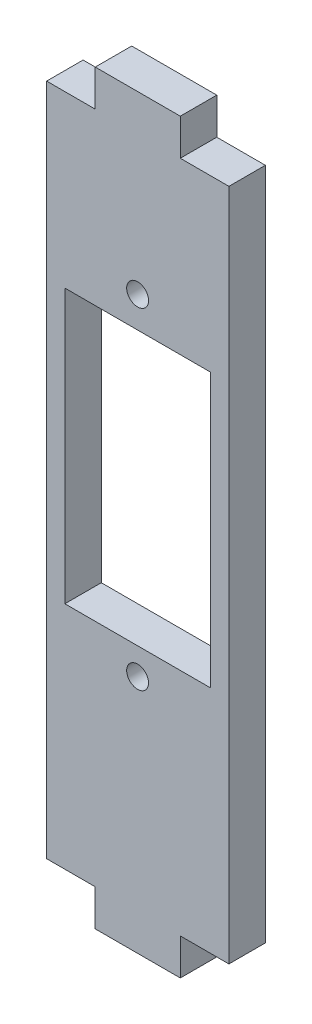
from build123d import *

# Parameters (mm, degrees)
SKETCH1_W               = 15
SKETCH1_H               = 61.42
BOSS_EXTRUDE2_DEPTH     = 3
SKETCH4_W               = 4
SKETCH4_H               = 3
CUT_EXTRUDE2_DEPTH      = 3
MIRROR2_COPY_1_SKETCH_W = 4
MIRROR2_COPY_1_SKETCH_H = 3
MIRROR2_COPY_1_DEPTH    = 3
SKETCH5_W               = 12
SKETCH5_H               = 22.5
CUT_EXTRUDE3_DEPTH      = 3
SKETCH7_R               = 0.9
CUT_EXTRUDE4_DEPTH      = 4


with BuildPart() as part:
    # Sketch1 → Boss-Extrude2 (new body)
    with BuildSketch(Plane.XY):
        Rectangle(SKETCH1_W, SKETCH1_H)
    extrude(amount=BOSS_EXTRUDE2_DEPTH)

    # Sketch4 → Cut-Extrude2 (cut)
    with BuildSketch(Plane.XY.offset(3)):
        with Locations((-5.5, 29.21)):
            Rectangle(SKETCH4_W, SKETCH4_H)
    cut_extrude2 = extrude(amount=-CUT_EXTRUDE2_DEPTH, mode=Mode.SUBTRACT)

    # Mirror1: Cut-Extrude2 across plane
    add(cut_extrude2.mirror(Plane(origin=(0, 0, 0), x_dir=(0, 0, 1), z_dir=(1, 0, 0))), mode=Mode.SUBTRACT)

    # Mirror2: Cut-Extrude2 across plane
    add(cut_extrude2.mirror(Plane.ZX), mode=Mode.SUBTRACT)

    # Mirror2 copy 1 sketch → Mirror2 copy 1 (cut)
    with BuildSketch(Plane(origin=(0, 0, 3), x_dir=(-1, 0, 0), z_dir=(0, 0, 1))):
        with Locations((-5.5, 29.21)):
            Rectangle(MIRROR2_COPY_1_SKETCH_W, MIRROR2_COPY_1_SKETCH_H)
    extrude(amount=-MIRROR2_COPY_1_DEPTH, mode=Mode.SUBTRACT)

    # Sketch5 → Cut-Extrude3 (cut)
    with BuildSketch(Plane.XY.offset(3)):
        with Locations((0, 2.46)):
            Rectangle(SKETCH5_W, SKETCH5_H)
    extrude(amount=-CUT_EXTRUDE3_DEPTH, mode=Mode.SUBTRACT)

    # Sketch7 → Cut-Extrude4 (cut, through all)
    with BuildSketch(Plane(origin=(0, 0, 0), x_dir=(-1, 0, 0), z_dir=(0, 0, -1))):
        with Locations((0.012913573, 16.255029587)):
            Circle(SKETCH7_R)
        with Locations((0.012913573, -10.994970413)):
            Circle(SKETCH7_R)
    extrude(amount=-CUT_EXTRUDE4_DEPTH, mode=Mode.SUBTRACT)


solid = part.part
